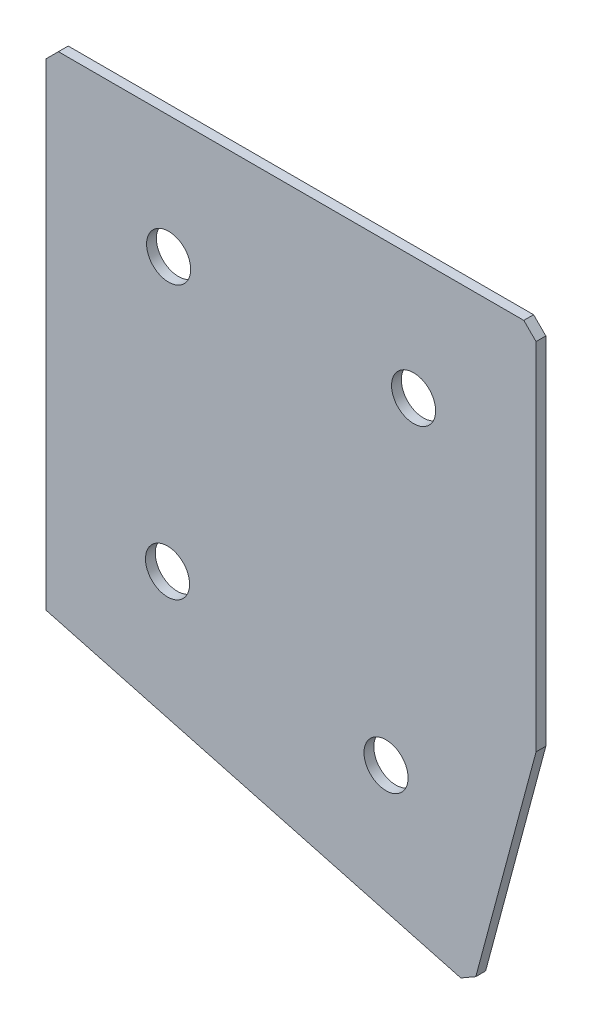
from build123d import *

# Parameters (mm, degrees)
EXTRUDE_1_DEPTH   = 2
HOLE_WIZARD_M81_D = 9
CHAMFER_1_SIZE    = 2.5


with BuildPart() as part:
    # Эскиз3 → Бобышка-Вытянуть1 (new body)
    with BuildSketch(Plane(origin=(0, 0, 0), x_dir=(1, 0, 0), z_dir=(0, 0, -1))):
        Polygon((0, 0), (100, 0), (100, 75.031110223), (87.059047745, 123.327401537), (0, 100), align=None)
    extrude(amount=EXTRUDE_1_DEPTH)

    # Отверстие с зазором M81 (through all)
    with Locations(Plane(origin=(0, 0, -2), x_dir=(1, 0, 0), z_dir=(0, 0, -1))):
        with Locations((75, 25), (24.776246401, 80.756870704), (69.381378215, 92.708779752), (25, 25)):
            Hole(HOLE_WIZARD_M81_D / 2)

    # Фаска1
    chamfer_1_edges = [part.edges().sort_by_distance(p)[0] for p in [
        (87.059047745, -123.327401537, -1),
        (100, 0, -1),
        (0, 0, -1),
    ]]
    chamfer(chamfer_1_edges, length=CHAMFER_1_SIZE)


solid = part.part
